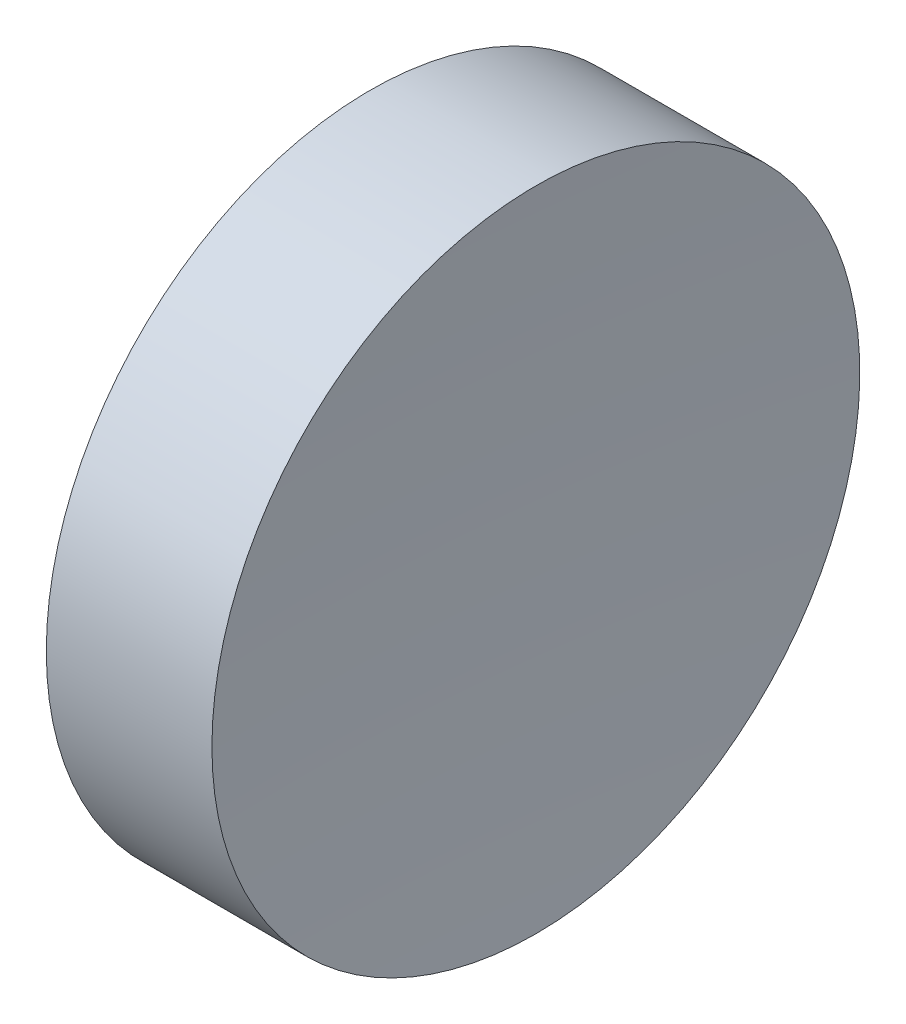
from build123d import *


with BuildPart() as part:
    # 草图1 → 旋转1 (revolve)
    with BuildSketch(Plane.XY, mode=Mode.PRIVATE) as revolve_1_sk:
        with BuildLine():
            Line((57.546327767, 34.689010562), (57.546327767, 40.939010562))
            Line((57.546327767, 40.939010562), (60.741831516, 40.939010562))
            ThreePointArc((60.741831516, 40.939010562), (60.59521576, 37.815539054), (60.546327908, 34.689010562))
            Line((60.546327908, 34.689010562), (57.546327767, 34.689010562))
        make_face()
    revolve(revolve_1_sk.sketch.rotate(Axis((54.492571501, 34.689010562, 0), (1, 0, 0)), 180), axis=Axis((54.492571501, 34.689010562, 0), (1, 0, 0)))  # turned: the seam where the file's is


solid = part.part
